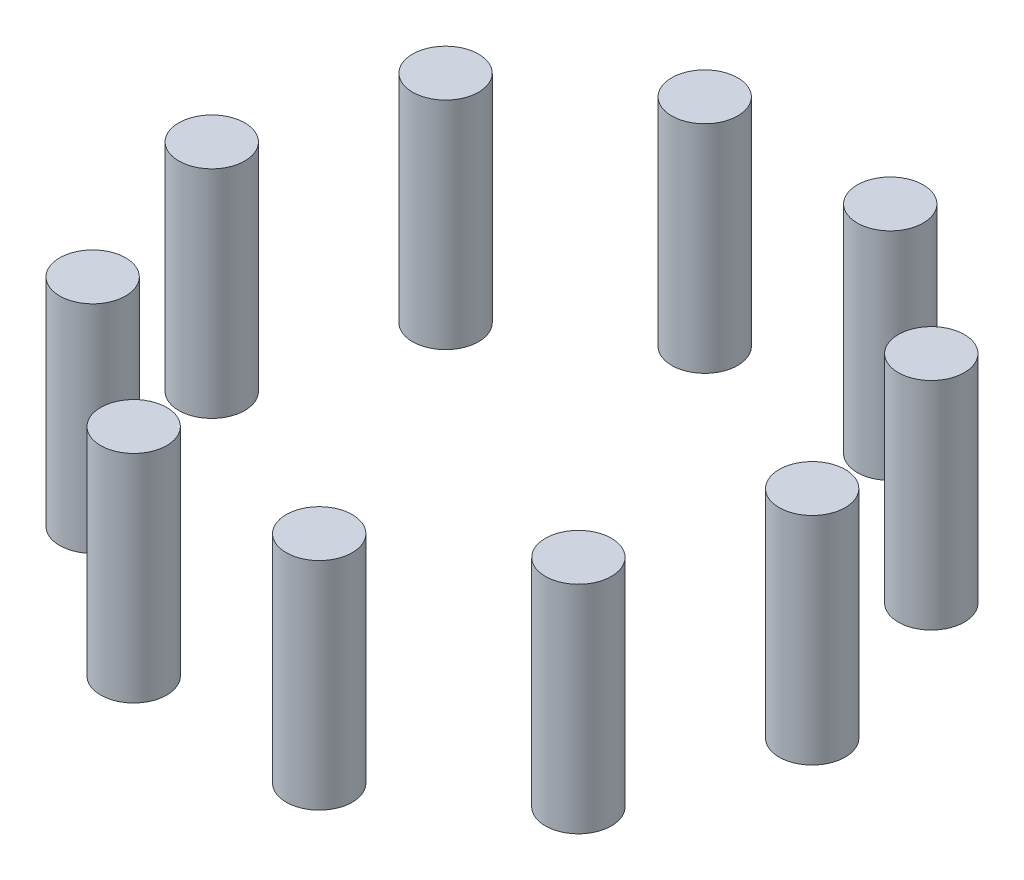
from build123d import *

# Parameters (mm, degrees)
SKETCH1_R              = 5.5
BOSS_EXTRUDE1_DEPTH    = 36
BOSS_EXTRUDE1_2_DEPTH  = 36
BOSS_EXTRUDE1_3_DEPTH  = 36
BOSS_EXTRUDE1_4_DEPTH  = 36
BOSS_EXTRUDE1_5_DEPTH  = 36
BOSS_EXTRUDE1_6_DEPTH  = 36
BOSS_EXTRUDE1_7_DEPTH  = 36
BOSS_EXTRUDE1_8_DEPTH  = 36
BOSS_EXTRUDE1_9_DEPTH  = 36
BOSS_EXTRUDE1_10_DEPTH = 36


with BuildPart() as part:
    # Sketch1 → Boss-Extrude1 (new body)
    with BuildSketch(Plane(origin=(0, 0, 0), x_dir=(1, 0, 0), z_dir=(0, 1, 0))):
        with Locations((50, 0)):
            Circle(SKETCH1_R)
    extrude(amount=BOSS_EXTRUDE1_DEPTH)


with BuildPart() as body_2:
    # Sketch1 → Boss-Extrude1 2 (new body)
    with BuildSketch(Plane(origin=(0, 0, 0), x_dir=(1, 0, 0), z_dir=(0, 1, 0))):
        with Locations((40.450849719, -29.389262615)):
            Circle(SKETCH1_R)
    extrude(amount=BOSS_EXTRUDE1_2_DEPTH)


with BuildPart() as body_3:
    # Sketch1 → Boss-Extrude1 3 (new body)
    with BuildSketch(Plane(origin=(0, 0, 0), x_dir=(1, 0, 0), z_dir=(0, 1, 0))):
        with Locations((15.450849719, -47.552825815)):
            Circle(SKETCH1_R)
    extrude(amount=BOSS_EXTRUDE1_3_DEPTH)


with BuildPart() as body_4:
    # Sketch1 → Boss-Extrude1 4 (new body)
    with BuildSketch(Plane(origin=(0, 0, 0), x_dir=(1, 0, 0), z_dir=(0, 1, 0))):
        with Locations((-15.450849719, -47.552825815)):
            Circle(SKETCH1_R)
    extrude(amount=BOSS_EXTRUDE1_4_DEPTH)


with BuildPart() as body_5:
    # Sketch1 → Boss-Extrude1 5 (new body)
    with BuildSketch(Plane(origin=(0, 0, 0), x_dir=(1, 0, 0), z_dir=(0, 1, 0))):
        with Locations((-40.450849719, -29.389262615)):
            Circle(SKETCH1_R)
    extrude(amount=BOSS_EXTRUDE1_5_DEPTH)


with BuildPart() as body_6:
    # Sketch1 → Boss-Extrude1 6 (new body)
    with BuildSketch(Plane(origin=(0, 0, 0), x_dir=(1, 0, 0), z_dir=(0, 1, 0))):
        with Locations((-50, 0)):
            Circle(SKETCH1_R)
    extrude(amount=BOSS_EXTRUDE1_6_DEPTH)


with BuildPart() as body_7:
    # Sketch1 → Boss-Extrude1 7 (new body)
    with BuildSketch(Plane(origin=(0, 0, 0), x_dir=(1, 0, 0), z_dir=(0, 1, 0))):
        with Locations((-40.450849719, 29.389262615)):
            Circle(SKETCH1_R)
    extrude(amount=BOSS_EXTRUDE1_7_DEPTH)


with BuildPart() as body_8:
    # Sketch1 → Boss-Extrude1 8 (new body)
    with BuildSketch(Plane(origin=(0, 0, 0), x_dir=(1, 0, 0), z_dir=(0, 1, 0))):
        with Locations((-15.450849719, 47.552825815)):
            Circle(SKETCH1_R)
    extrude(amount=BOSS_EXTRUDE1_8_DEPTH)


with BuildPart() as body_9:
    # Sketch1 → Boss-Extrude1 9 (new body)
    with BuildSketch(Plane(origin=(0, 0, 0), x_dir=(1, 0, 0), z_dir=(0, 1, 0))):
        with Locations((15.450849719, 47.552825815)):
            Circle(SKETCH1_R)
    extrude(amount=BOSS_EXTRUDE1_9_DEPTH)


with BuildPart() as body_10:
    # Sketch1 → Boss-Extrude1 10 (new body)
    with BuildSketch(Plane(origin=(0, 0, 0), x_dir=(1, 0, 0), z_dir=(0, 1, 0))):
        with Locations((40.450849719, 29.389262615)):
            Circle(SKETCH1_R)
    extrude(amount=BOSS_EXTRUDE1_10_DEPTH)


solid = Compound([part.part, body_2.part, body_3.part, body_4.part, body_5.part, body_6.part, body_7.part, body_8.part, body_9.part, body_10.part])
